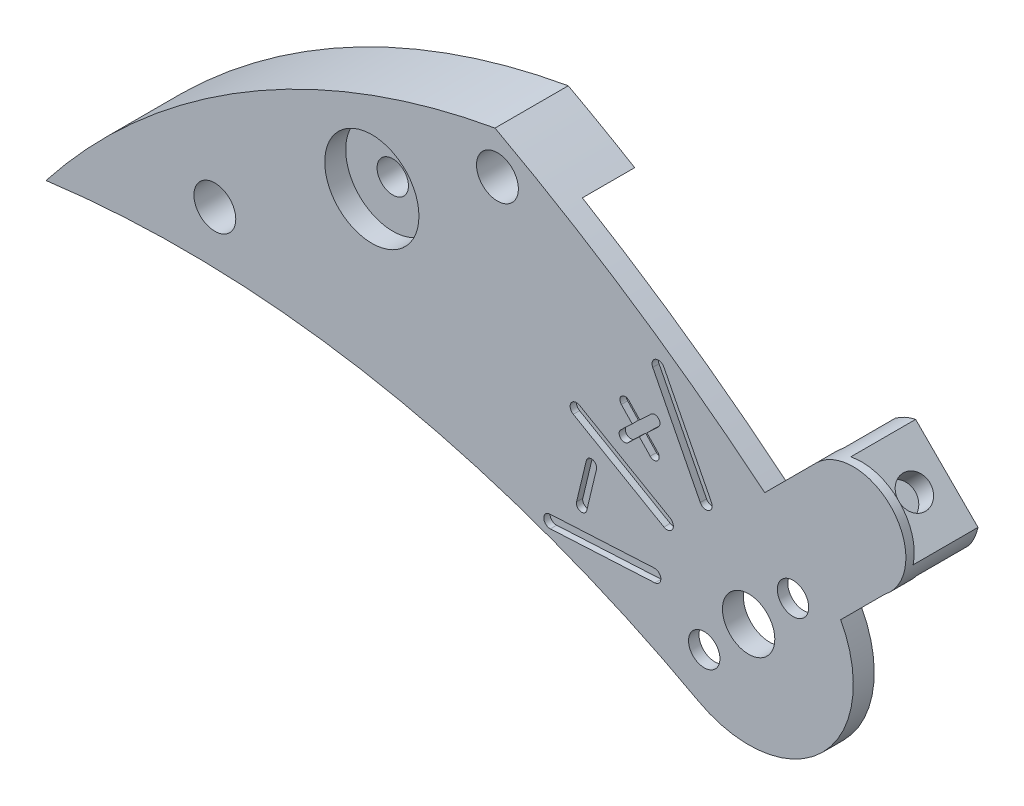
from build123d import *

# Parameters (mm, degrees)
CROQUIS1_R                 = 0.625
CROQUIS1_R_2               = 0.5
SALIENTE_EXTRUIR1_DEPTH    = 1.75
CROQUIS2_R                 = 7.75
CORTAR_EXTRUIR1_DEPTH      = 1.25
SALIENTE_EXTRUIR2_DEPTH    = 1.25
CORTAR_EXTRUIR2_DEPTH      = 0.3
CROQUIS5_R                 = 0.75
CORTAR_EXTRUIR3_DEPTH      = 0.25
CROQUIS7_R                 = 1.125
CORTAR_EXTRUIR4_DEPTH      = 0.5
CORTAR_EXTRUIR5_DEPTH      = 0.15
M1X0_25_TAPPED_HOLE1_D     = 0.75
M1X0_25_TAPPED_HOLE2_D     = 0.75
M1X0_25_TAPPED_HOLE3_D     = 0.75
M1X0_25_TAPPED_HOLE3_DEPTH = 0.5


with BuildPart() as part:
    # Croquis1 → Saliente-Extruir1 (new body)
    with BuildSketch(Plane.XY):
        with BuildLine():
            Line((6.259644122, 12.249974926), (5.198983951, 11.189314754))
            ThreePointArc((5.198983951, 11.189314754), (4.763256008, 8.227733584), (1.799492386, 7.807106599))
            ThreePointArc((1.799492386, 7.807106599), (-0.79068784, 9.047504388), (-3.5, 10))
            ThreePointArc((-3.5, 10), (-8.600559157, 10.927738054), (-13.78279853, 10.783527469))
            ThreePointArc((-13.78279853, 10.783527469), (-9.016404165, 14.998481788), (-3.058096956, 17.230729613))
            ThreePointArc((-3.058096956, 17.230729613), (0.268930152, 15.227921239), (3.386067713, 12.911932422))
            Line((3.386067713, 12.911932422), (4.62350458, 14.14936929))
            ThreePointArc((4.62350458, 14.14936929), (6.451492666, 14.069616403), (6.259644122, 12.249974926))
        make_face()
        with Locations((3, 10)):
            Circle(CROQUIS1_R, mode=Mode.SUBTRACT)
        with Locations((-3, 16.25)):
            Circle(CROQUIS1_R_2, mode=Mode.SUBTRACT)
        with Locations((-9.75, 12.25)):
            Circle(CROQUIS1_R_2, mode=Mode.SUBTRACT)
    extrude(amount=SALIENTE_EXTRUIR1_DEPTH)

    # Croquis2 → Cortar-Extruir1 (cut)
    with BuildSketch(Plane(origin=(0, 0, 0), x_dir=(-1, 0, 0), z_dir=(0, 0, -1))):
        with Locations((-3, 10)):
            Circle(CROQUIS2_R)
    extrude(amount=-CORTAR_EXTRUIR1_DEPTH, mode=Mode.SUBTRACT)

    # Croquis3 → Saliente-Extruir2 (add)
    with BuildSketch(Plane(origin=(0, 0, 1.25), x_dir=(-1, 0, 0), z_dir=(0, 0, -1))):
        Polygon((-5.272601551, 12.323592527), (-4.56549477, 13.030699308), (-4.91904816, 13.384252698), (-5.626154942, 12.677145917), align=None)
        with BuildLine():
            Line((-6.508612401, 12.501795239), (-4.751795239, 14.258612401))
            ThreePointArc((-4.751795239, 14.258612401), (-4.983609366, 14.394748904), (-5.239087061, 14.47842736))
            Line((-5.239087061, 14.47842736), (-6.72842736, 12.989087061))
            ThreePointArc((-6.72842736, 12.989087061), (-6.644748904, 12.733609366), (-6.508612401, 12.501795239))
        make_face()
    extrude(amount=SALIENTE_EXTRUIR2_DEPTH)

    # Croquis4 → Cortar-Extruir2 (cut)
    with BuildSketch(Plane(origin=(0, 0, 1.25), x_dir=(-1, 0, 0), z_dir=(0, 0, -1))):
        with BuildLine():
            Line((-5.239087061, 14.47842736), (-6.72842736, 12.989087061))
            ThreePointArc((-6.72842736, 12.989087061), (-6.388006008, 14.138006008), (-5.239087061, 14.47842736))
        make_face()
    extrude(amount=-CORTAR_EXTRUIR2_DEPTH, mode=Mode.SUBTRACT)

    # Croquis5 → Cortar-Extruir3 (cut)
    with BuildSketch(Plane(origin=(0, 0, 1.25), x_dir=(-1, 0, 0), z_dir=(0, 0, -1))):
        with Locations((-4.060660172, 11.060660172)):
            Circle(CROQUIS5_R)
        with Locations((-1.939339828, 8.939339828)):
            Circle(CROQUIS5_R)
    extrude(amount=-CORTAR_EXTRUIR3_DEPTH, mode=Mode.SUBTRACT)

    # Croquis7 → Cortar-Extruir4 (cut)
    with BuildSketch(Plane.XY.offset(1.75)):
        with Locations((-6, 14.5)):
            Circle(CROQUIS7_R)
    extrude(amount=-CORTAR_EXTRUIR4_DEPTH, mode=Mode.SUBTRACT)

    # Croquis8 → Cortar-Extruir5 (cut)
    with BuildSketch(Plane.XY.offset(1.75)):
        with BuildLine():
            Line((0.977196105, 14.300379565), (2.112172354, 12.072863254))
            ThreePointArc((2.112172354, 12.072863254), (2.046619951, 11.871113701), (1.844870397, 11.936666104))
            Line((1.844870397, 11.936666104), (0.709894148, 14.164182415))
            ThreePointArc((0.709894148, 14.164182415), (0.775446551, 14.365931969), (0.977196105, 14.300379565))
        make_face()
        with BuildLine():
            Line((0.76093394, 9.732449668), (-1.735639897, 9.601609778))
            ThreePointArc((-1.735639897, 9.601609778), (-1.89328472, 9.743553814), (-1.751340684, 9.901198638))
            Line((-1.751340684, 9.901198638), (0.745233153, 10.032038529))
            ThreePointArc((0.745233153, 10.032038529), (0.902877977, 9.890094492), (0.76093394, 9.732449668))
        make_face()
        with BuildLine():
            Line((-1.038620668, 12.504903811), (1.126442841, 11.254903811))
            ThreePointArc((1.126442841, 11.254903811), (1.181346652, 11.05), (0.976442841, 10.995096189))
            Line((0.976442841, 10.995096189), (-1.188620668, 12.245096189))
            ThreePointArc((-1.188620668, 12.245096189), (-1.243524479, 12.45), (-1.038620668, 12.504903811))
        make_face()
        with BuildLine():
            Line((-0.633682247, 11.386577522), (-0.867127611, 10.414207601))
            ThreePointArc((-0.867127611, 10.414207601), (-1.017854522, 10.321842032), (-1.110220091, 10.472568942))
            Line((-1.110220091, 10.472568942), (-0.876774727, 11.444938863))
            ThreePointArc((-0.876774727, 11.444938863), (-0.726047817, 11.537304432), (-0.633682247, 11.386577522))
        make_face()
        with BuildLine():
            Line((-0.053831977, 12.491697608), (0.218183412, 12.749830574))
            Line((0.218183412, 12.749830574), (-0.039949554, 13.021845963))
            ThreePointArc((-0.039949554, 13.021845963), (-0.03532208, 13.198562081), (0.141394039, 13.193934607))
            Line((0.141394039, 13.193934607), (0.399527005, 12.921919218))
            Line((0.399527005, 12.921919218), (0.671542394, 13.180052184))
            ThreePointArc((0.671542394, 13.180052184), (0.848258512, 13.175424709), (0.843631038, 12.998708591))
            Line((0.843631038, 12.998708591), (0.571615649, 12.740575625))
            Line((0.571615649, 12.740575625), (0.829748614, 12.468560236))
            ThreePointArc((0.829748614, 12.468560236), (0.82512114, 12.291844118), (0.648405022, 12.296471592))
            Line((0.648405022, 12.296471592), (0.390272056, 12.568486981))
            Line((0.390272056, 12.568486981), (0.118256667, 12.310354015))
            ThreePointArc((0.118256667, 12.310354015), (-0.058459452, 12.31498149), (-0.053831977, 12.491697608))
        make_face()
    extrude(amount=-CORTAR_EXTRUIR5_DEPTH, mode=Mode.SUBTRACT)

    # M1x0.25 Tapped Hole1 (through all)
    with Locations(Plane(origin=(0, 0, 1.5), x_dir=(-1, 0, 0), z_dir=(0, 0, -1))):
        with Locations((-1.939339828, 8.939339828), (-4.060660172, 11.060660172)):
            Hole(M1X0_25_TAPPED_HOLE1_D / 2)

    # M1x0.25 Tapped Hole2 (through all)
    with Locations(Plane.XY.offset(1.25)):
        with Locations((-6, 14.5)):
            Hole(M1X0_25_TAPPED_HOLE2_D / 2)

    # M1x0.25 Tapped Hole3
    with Locations(Plane(origin=(9.858757211, 9.858757211, 0), x_dir=(-0.707106781, 0.707106781, 0), z_dir=(0.707106781, 0.707106781, 0))):
        with Locations((5.480077554, 0.775)):
            Hole(M1X0_25_TAPPED_HOLE3_D / 2, depth=M1X0_25_TAPPED_HOLE3_DEPTH)


solid = part.part
